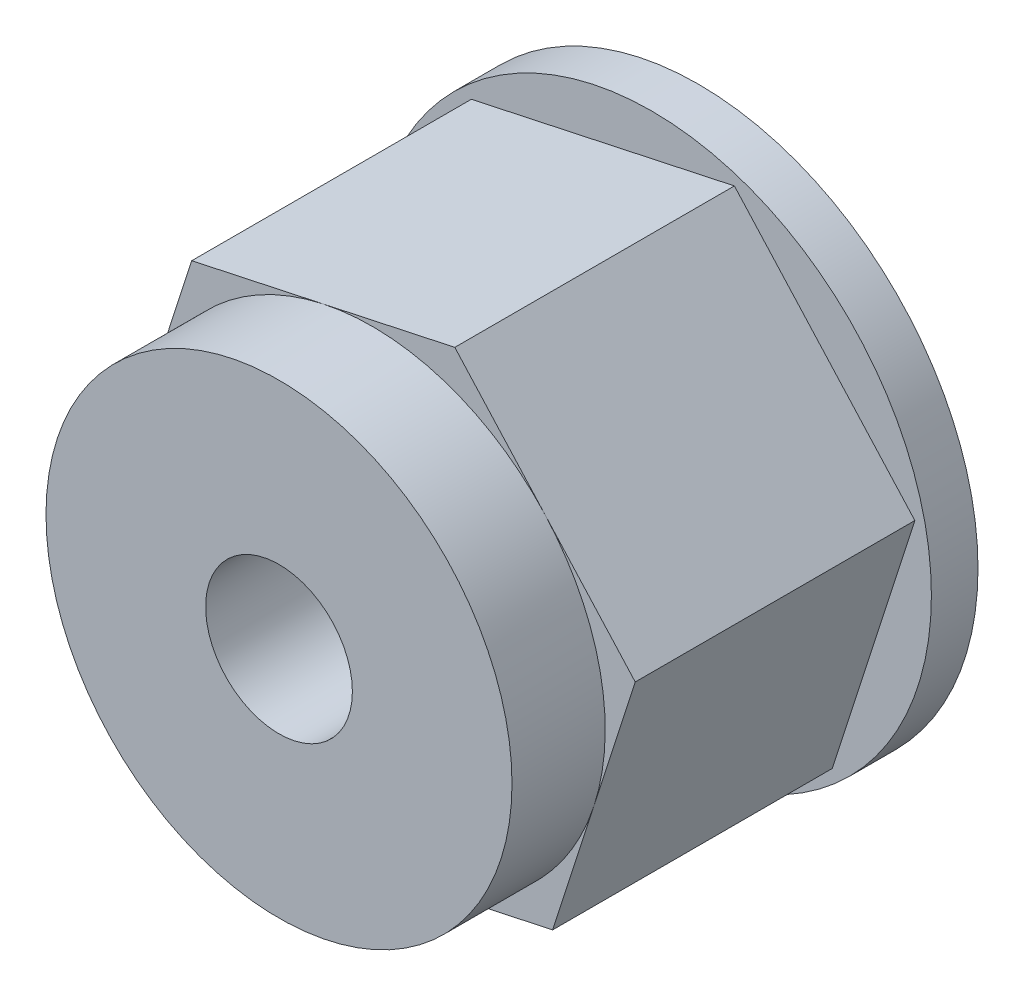
from build123d import *

# Parameters (mm, degrees)
SKETCH1_R               = 7.62
BOSS_EXTRUDE1_DEPTH     = 1.27
BOSS_EXTRUDE2_DEPTH     = 7.62
SKETCH4_R               = 6.35
BOSS_EXTRUDE3_DEPTH     = 2.54
SKETCH5_R               = 2
CUT_EXTRUDE1_DEPTH      = 1
CUT_EXTRUDE1_DEPTH_BACK = 12.43


with BuildPart() as part:
    # Sketch1 → Boss-Extrude1 (new body)
    with BuildSketch(Plane.XY):
        Circle(SKETCH1_R)
    extrude(amount=BOSS_EXTRUDE1_DEPTH)

    # Sketch2 → Boss-Extrude2 (add)
    with BuildSketch(Plane.XY.offset(1.27)):
        Polygon((4.917620463, -5.438781327), (7.168933026, 1.539393583), (2.251312563, 6.97817491), (-4.917620463, 5.438781327), (-7.168933026, -1.539393583), (-2.251312563, -6.97817491), align=None)
    extrude(amount=BOSS_EXTRUDE2_DEPTH)

    # Sketch4 → Boss-Extrude3 (add)
    with BuildSketch(Plane.XY.offset(8.89)):
        Circle(SKETCH4_R)
    extrude(amount=BOSS_EXTRUDE3_DEPTH)

    # Sketch5 → Cut-Extrude1 (cut, two sides)
    with BuildSketch(Plane.XY.offset(11.43)) as cut_extrude1_sk:
        Circle(SKETCH5_R)
    extrude(amount=CUT_EXTRUDE1_DEPTH, mode=Mode.SUBTRACT)
    extrude(cut_extrude1_sk.sketch, amount=-CUT_EXTRUDE1_DEPTH_BACK, mode=Mode.SUBTRACT)


solid = part.part
